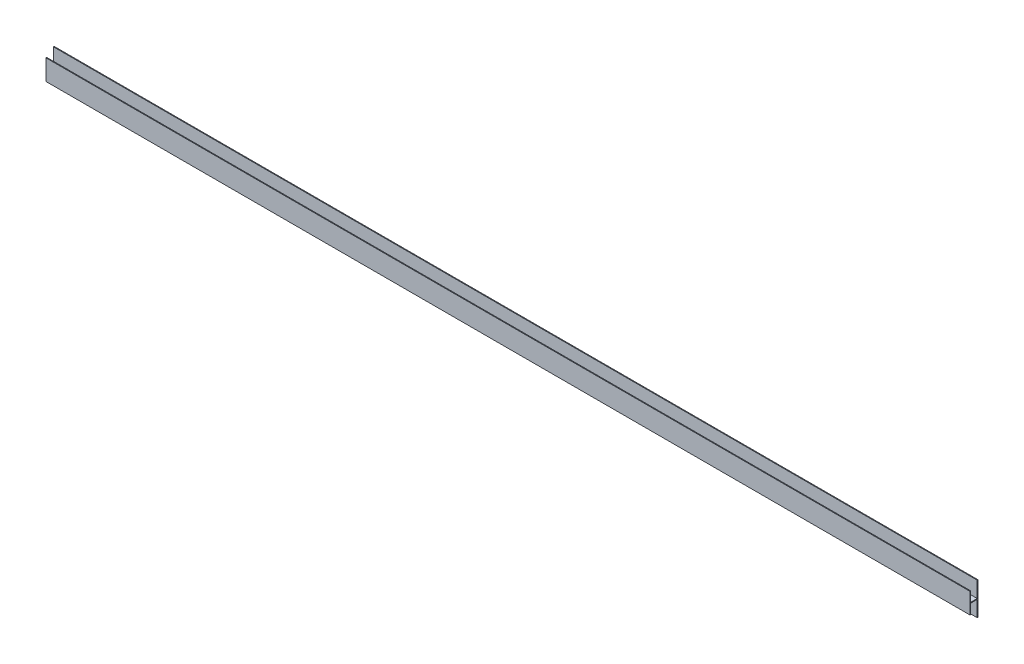
from build123d import *

# Parameters (mm, degrees)
BOSS_EXTRUDE1_DEPTH = 901.7


with BuildPart() as part:
    # Sketch1 → Boss-Extrude1 (new body, symmetric)
    with BuildSketch(Plane(origin=(0, 0, 0), x_dir=(0, 0, -1), z_dir=(1, 0, 0))):
        Polygon((-6.35, -0.75), (6.35, -0.75), (6.35, -31.75), (7.85, -31.75), (7.85, 31.75), (6.35, 31.75), (6.35, 0.75), (-6.35, 0.75), (-6.35, 20), (-7.85, 20), (-7.85, -20), (-6.35, -20), align=None)
    extrude(amount=BOSS_EXTRUDE1_DEPTH, both=True)


solid = part.part
